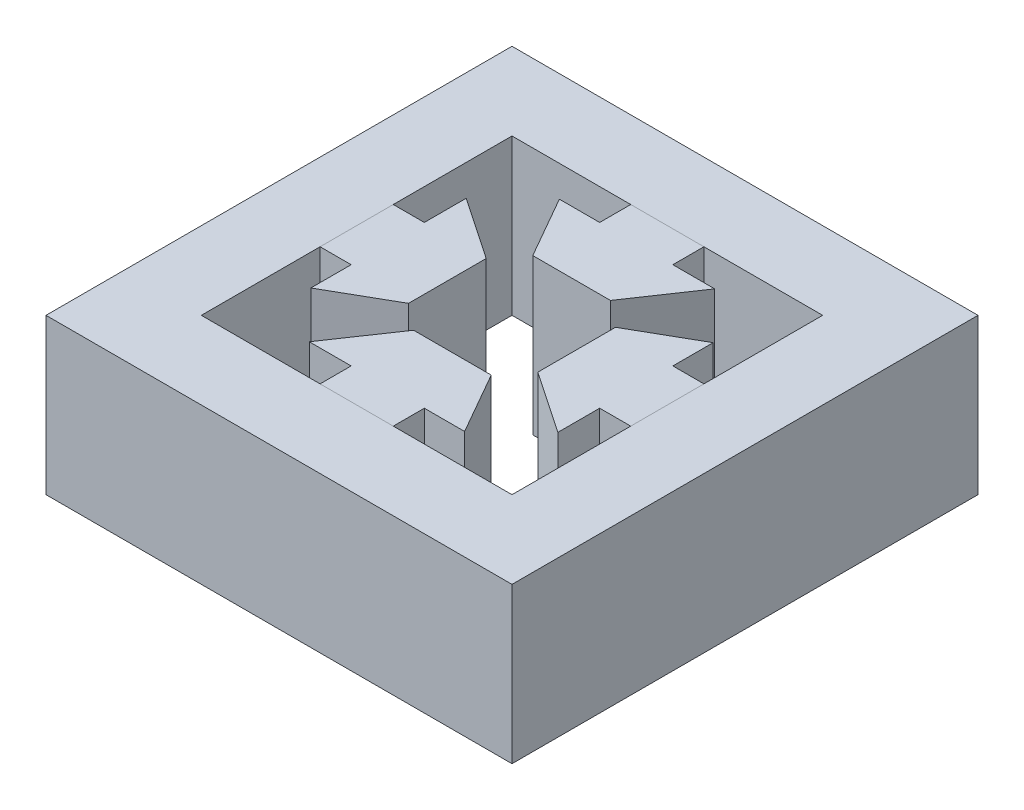
from build123d import *

# Parameters (mm, degrees)
SKETCH1_W           = 30
SKETCH1_H           = 30
SKETCH1_W_2         = 20
SKETCH1_H_2         = 20
BOSS_EXTRUDE1_DEPTH = 10
SKETCH2_W           = 4.711017494
SKETCH2_H           = 2
SKETCH2_W_2         = 2
SKETCH2_H_2         = 4.711017494
BOSS_EXTRUDE2_DEPTH = 10


with BuildPart() as part:
    # Sketch1 → Boss-Extrude1 (new body)
    with BuildSketch(Plane(origin=(0, 0, 0), x_dir=(1, 0, 0), z_dir=(0, 1, 0))):
        Rectangle(SKETCH1_W, SKETCH1_H)
        Rectangle(SKETCH1_W_2, SKETCH1_H_2, mode=Mode.SUBTRACT)
    extrude(amount=BOSS_EXTRUDE1_DEPTH)


with BuildPart() as body_2:
    # Sketch2 → Boss-Extrude2 (new body)
    with BuildSketch(Plane(origin=(0, 10, 0), x_dir=(1, 0, 0), z_dir=(0, 1, 0))):
        Polygon((2.336539675, 4), (-2.663460325, 4), (-4.950152781, 8), (5.049847219, 8), align=None)
        with Locations((0, 9)):
            Rectangle(SKETCH2_W, SKETCH2_H)
        Polygon((-4, 2.336539675), (-4, -2.663460325), (-8, -4.950152781), (-8, 5.049847219), align=None)
        Polygon((-2.336539675, -4), (2.663460325, -4), (4.950152781, -8), (-5.049847219, -8), align=None)
        with Locations((0, -9)):
            Rectangle(SKETCH2_W, SKETCH2_H)
        Polygon((4, 2.663460325), (4, -2.336539675), (8, -5.049847219), (8, -2.355508747), (8, 2.355508747), (8, 4.950152781), align=None)
        with Locations((9, 0)):
            Rectangle(SKETCH2_W_2, SKETCH2_H_2)
        with Locations((-9, 0)):
            Rectangle(SKETCH2_W_2, SKETCH2_H_2)
    extrude(amount=-BOSS_EXTRUDE2_DEPTH)


solid = Compound([part.part, body_2.part])
